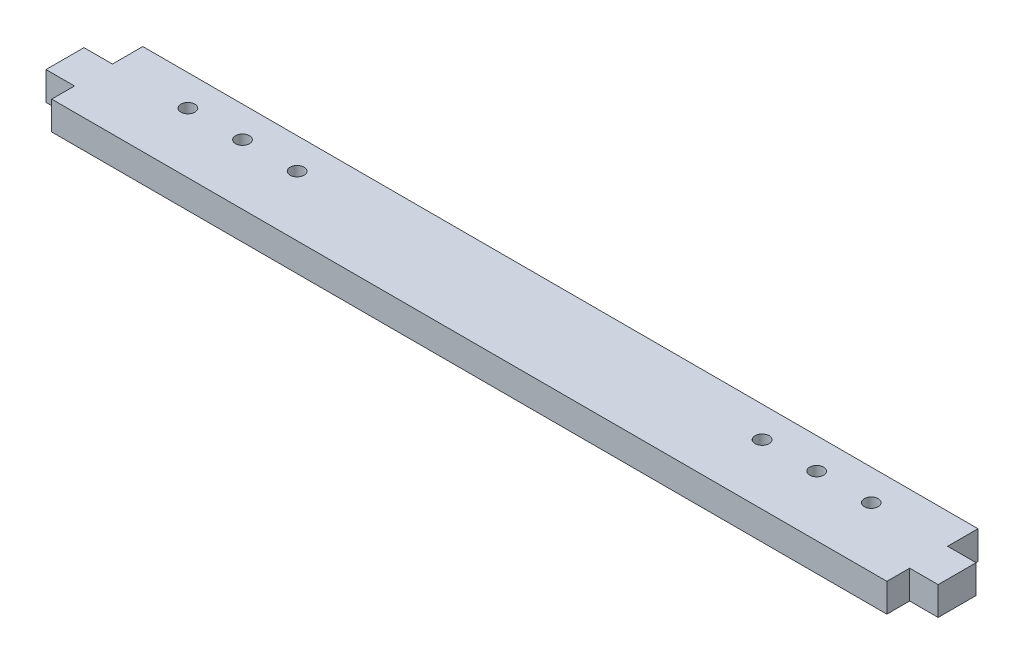
from build123d import *

# Parameters (mm, degrees)
SKETCH1_W           = 279.4
SKETCH1_H           = 30.48
BOSS_EXTRUDE1_DEPTH = 9.525
SKETCH2_W           = 12.7
SKETCH2_H           = 9.525
BOSS_EXTRUDE2_DEPTH = 9.525
SKETCH3_R           = 2.3368
CUT_EXTRUDE1_DEPTH  = 10.525


with BuildPart() as part:
    # Sketch1 → Boss-Extrude1 (new body)
    with BuildSketch(Plane(origin=(0, 0, 0), x_dir=(1, 0, 0), z_dir=(0, 1, 0))):
        Rectangle(SKETCH1_W, SKETCH1_H)
    extrude(amount=BOSS_EXTRUDE1_DEPTH)

    # Sketch2 → Boss-Extrude2 (add)
    with BuildSketch(Plane(origin=(139.7, 0, 0), x_dir=(0, 0, -1), z_dir=(1, 0, 0))):
        with Locations((-1.27, 4.7625)):
            Rectangle(SKETCH2_W, SKETCH2_H)
    boss_extrude2 = extrude(amount=BOSS_EXTRUDE2_DEPTH)

    # Mirror1: Boss-Extrude2 across plane
    add(boss_extrude2.mirror(Plane(origin=(0, 0, 0), x_dir=(0, 0, 1), z_dir=(1, 0, 0))))

    # Sketch3 → Cut-Extrude1 (cut, through all)
    with BuildSketch(Plane.XZ):
        with Locations((114.3, -4.9276)):
            Circle(SKETCH3_R)
        with Locations((77.7748, -4.9276)):
            Circle(SKETCH3_R)
        with Locations((96.0374, -4.9276)):
            Circle(SKETCH3_R)
    cut_extrude1 = extrude(amount=-CUT_EXTRUDE1_DEPTH, mode=Mode.SUBTRACT)

    # Mirror2: Cut-Extrude1 across plane
    add(cut_extrude1.mirror(Plane(origin=(0, 0, 0), x_dir=(0, 0, 1), z_dir=(1, 0, 0))), mode=Mode.SUBTRACT)


solid = part.part
